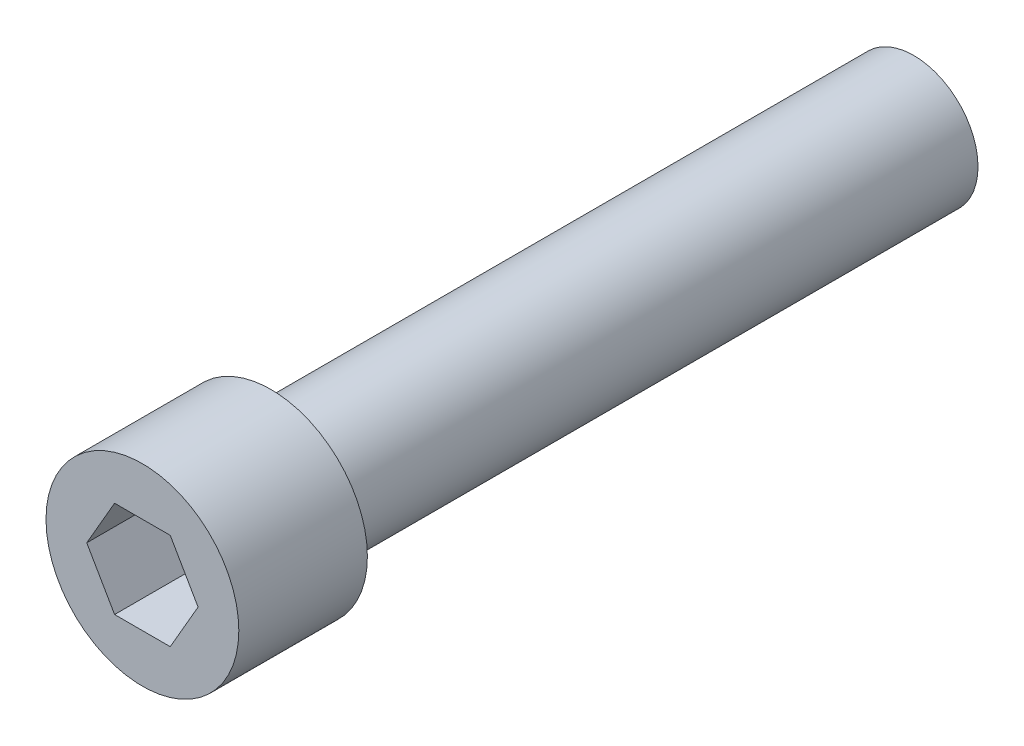
from build123d import *

# Parameters (mm, degrees)
SKETCH1_R           = 3.175
BOSS_EXTRUDE1_DEPTH = 31.75
SKETCH2_R           = 4.7625
BOSS_EXTRUDE2_DEPTH = 6.35
CUT_EXTRUDE1_DEPTH  = 3.5814


with BuildPart() as part:
    # Sketch1 → Boss-Extrude1 (new body)
    with BuildSketch(Plane.XY):
        Circle(SKETCH1_R)
    extrude(amount=BOSS_EXTRUDE1_DEPTH)

    # Sketch2 → Boss-Extrude2 (add)
    with BuildSketch(Plane.XY.offset(31.75)):
        Circle(SKETCH2_R)
    extrude(amount=BOSS_EXTRUDE2_DEPTH)

    # Sketch3 → Cut-Extrude1 (cut)
    with BuildSketch(Plane.XY.offset(38.1)):
        Polygon((2.749630657, 0), (1.374815329, 2.38125), (-1.374815329, 2.38125), (-2.749630657, 0), (-1.374815329, -2.38125), (1.374815329, -2.38125), align=None)
    extrude(amount=-CUT_EXTRUDE1_DEPTH, mode=Mode.SUBTRACT)


solid = part.part
